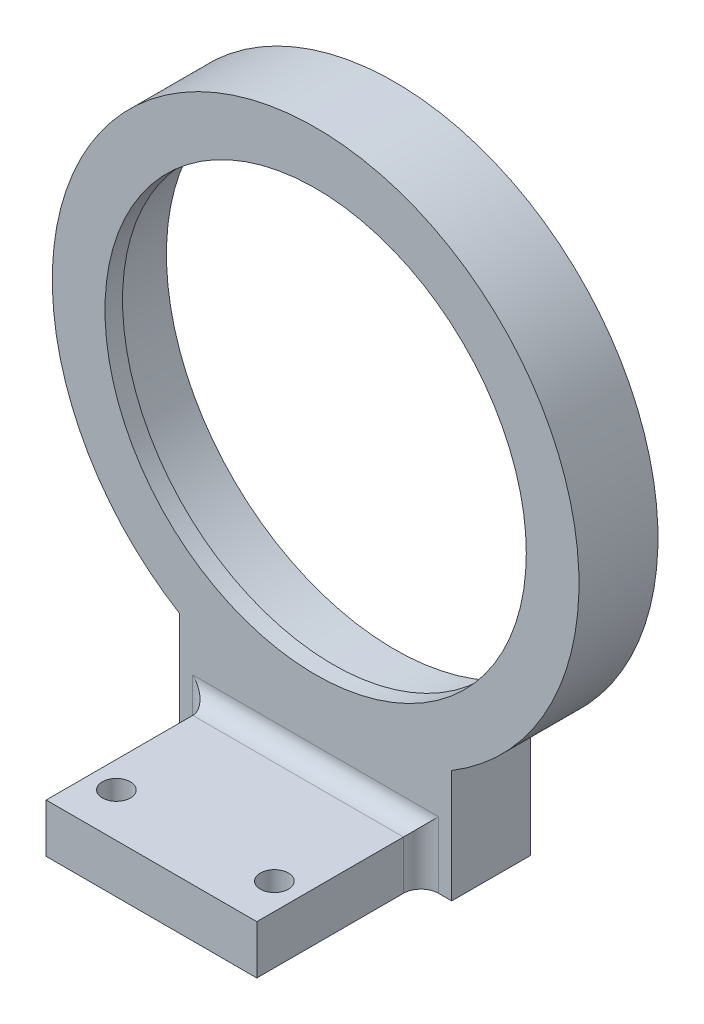
from build123d import *

# Parameters (mm, degrees)
SKETCH_1_R          = 26
EXTRUDE_1_DEPTH     = 7
SKETCH_4_R          = 30
SKETCH_4_R_2        = 24
EXTRUDE_4_DEPTH     = 2
SKETCH_5_W          = 24
SKETCH_5_H          = 5
EXTRUDE_5_DEPTH     = 20.7
EXTRUDE_6_DEPTH     = 2
EXTRUDE_7_DEPTH     = 0.56
SKETCH_7_R          = 1.6
CUT_EXTRUDE_1_DEPTH = 16
FILLET_1_R          = 2
FILLET_2_R          = 2
FILLET_3_R          = 2


with BuildPart() as part:
    # 草图1 → 凸台-拉伸1 (new body)
    with BuildSketch(Plane.XY):
        with BuildLine():
            Line((-15.5, -38), (15.5, -38))
            Line((15.5, -38), (15.5, -25.685599078))
            ThreePointArc((15.5, -25.685599078), (0, 30), (-15.5, -25.685599078))
            Line((-15.5, -25.685599078), (-15.5, -38))
        make_face()
        Circle(SKETCH_1_R, mode=Mode.SUBTRACT)
    extrude(amount=EXTRUDE_1_DEPTH)

    # 草图4 → 凸台-拉伸4 (add)
    with BuildSketch(Plane.XY.offset(7)):
        Circle(SKETCH_4_R)
        Circle(SKETCH_4_R_2, mode=Mode.SUBTRACT)
    extrude(amount=EXTRUDE_4_DEPTH)

    # 草图5 → 凸台-拉伸5 (add)
    with BuildSketch(Plane.XY.offset(7)):
        with Locations((0, -35.5)):
            Rectangle(SKETCH_5_W, SKETCH_5_H)
    extrude(amount=EXTRUDE_5_DEPTH)

    # 草图6 → 凸台-拉伸6 (add)
    with BuildSketch(Plane.XY.offset(7)):
        with BuildLine():
            Line((-15.5, -25.685599078), (-15.5, -38))
            Line((-15.5, -38), (-12, -38))
            Line((-12, -38), (-12, -33))
            Line((-12, -33), (12, -33))
            Line((12, -33), (12, -38))
            Line((12, -38), (15.5, -38))
            Line((15.5, -38), (15.5, -25.685599078))
            ThreePointArc((15.5, -25.685599078), (0, -30), (-15.5, -25.685599078))
        make_face()
    extrude(amount=EXTRUDE_6_DEPTH)

    # 草图9 → 凸台-拉伸7 (add)
    with BuildSketch(Plane.XZ.offset(38)):
        Polygon((15.5, 0), (15.5, 9), (12, 9), (12, 27.7), (-12, 27.7), (-12, 9), (-15.5, 9), (-15.5, 0), align=None)
    extrude(amount=EXTRUDE_7_DEPTH)

    # 草图7 → 切除-拉伸1 (cut)
    with BuildSketch(Plane(origin=(0, -33, 0), x_dir=(1, 0, 0), z_dir=(0, 1, 0))):
        with Locations((9, -22.7)):
            Circle(SKETCH_7_R)
        with Locations((-9, -22.7)):
            Circle(SKETCH_7_R)
    extrude(amount=-CUT_EXTRUDE_1_DEPTH, mode=Mode.SUBTRACT)

    # 圆角1
    fillet_1_edges = [part.edges().sort_by_distance(p)[0] for p in [
        (0, -33, 9),
    ]]
    fillet(fillet_1_edges, radius=FILLET_1_R)

    # 圆角2
    fillet_2_edges = [part.edges().sort_by_distance(p)[0] for p in [
        (12, -35.78, 9),
    ]]
    fillet(fillet_2_edges, radius=FILLET_2_R)

    # 圆角3
    fillet_3_edges = [part.edges().sort_by_distance(p)[0] for p in [
        (-12, -35.78, 9),
    ]]
    fillet(fillet_3_edges, radius=FILLET_3_R)


solid = part.part
